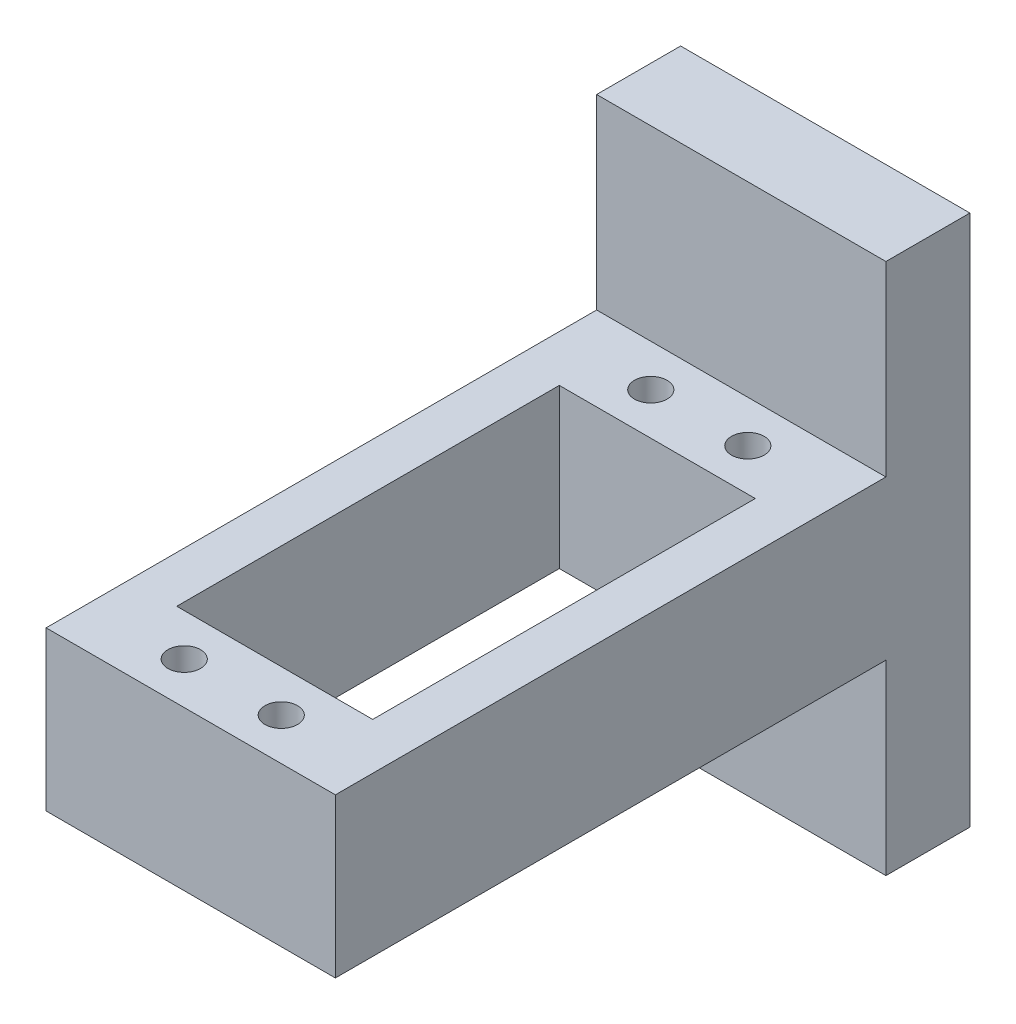
from build123d import *

# Parameters (mm, degrees)
BOSS_EXTRUDE1_DEPTH = 9
SKETCH10_W          = 31
SKETCH10_H          = 17
BOSS_EXTRUDE5_DEPTH = 59
SKETCH11_R          = 1.75
SKETCH11_W          = 21
SKETCH11_H          = 41
CUT_EXTRUDE6_DEPTH  = 38
SKETCH12_R          = 1.75
CUT_EXTRUDE7_DEPTH  = 3


with BuildPart() as part:
    # Sketch1 → Boss-Extrude1 (new body)
    with BuildSketch(Plane.XY):
        Polygon((15.5, -28.5), (-15.5, -28.5), (-15.5, -10.3), (-15.5, 10.3), (-15.5, 28.5), (15.5, 28.5), align=None)
    extrude(amount=BOSS_EXTRUDE1_DEPTH)

    # Sketch10 → Boss-Extrude5 (add)
    with BuildSketch(Plane.XY.offset(9)):
        Rectangle(SKETCH10_W, SKETCH10_H)
    extrude(amount=BOSS_EXTRUDE5_DEPTH)

    # Sketch11 → Cut-Extrude6 (cut, through all)
    with BuildSketch(Plane.XZ.offset(8.5)):
        with Locations((5.2, 13.5)):
            Circle(SKETCH11_R)
        with Locations((-5.2, 13.5)):
            Circle(SKETCH11_R)
        with Locations((5.2, 63.5)):
            Circle(SKETCH11_R)
        with Locations((-5.2, 63.5)):
            Circle(SKETCH11_R)
        with Locations((0, 38.5)):
            Rectangle(SKETCH11_W, SKETCH11_H)
    extrude(amount=-CUT_EXTRUDE6_DEPTH, mode=Mode.SUBTRACT)

    # Sketch12 → Cut-Extrude7 (cut)
    with BuildSketch(Plane(origin=(0, 0, 0), x_dir=(-1, 0, 0), z_dir=(0, 0, -1))):
        with Locations((11.5, 25)):
            Circle(SKETCH12_R)
        with Locations((-11.5, 25)):
            Circle(SKETCH12_R)
        with Locations((11.5, -25)):
            Circle(SKETCH12_R)
        with Locations((-11.5, -25)):
            Circle(SKETCH12_R)
    extrude(amount=-CUT_EXTRUDE7_DEPTH, mode=Mode.SUBTRACT)


solid = part.part
